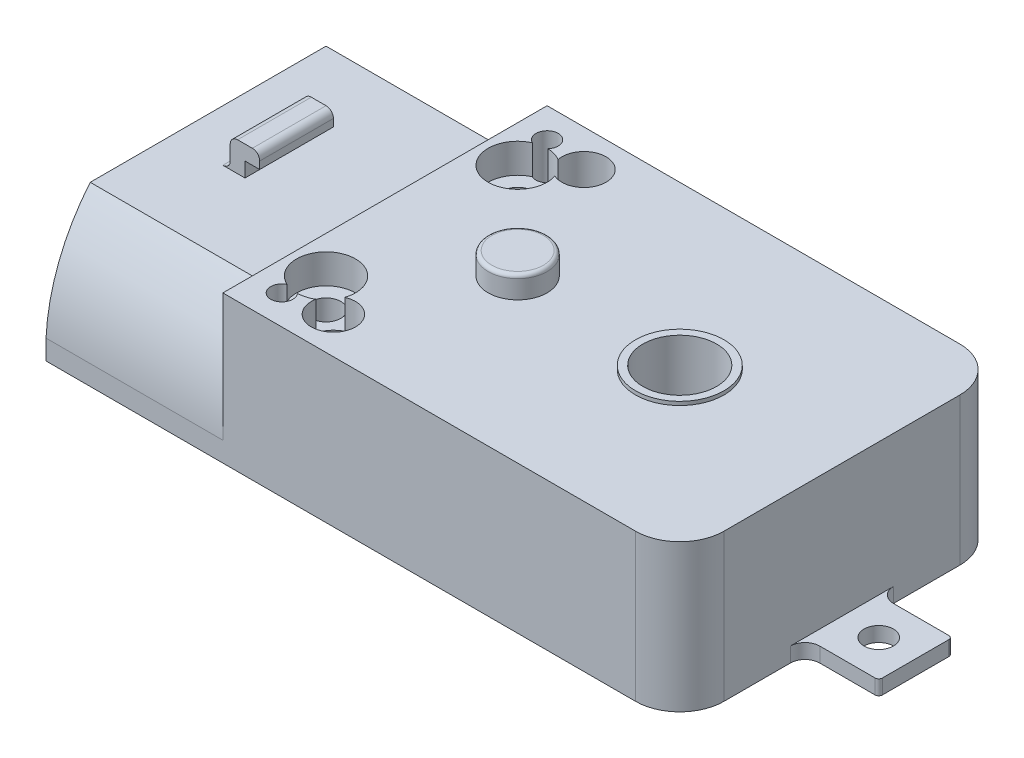
from build123d import *

# Parameters (mm, degrees)
BOSS_EXTRUDE2_DEPTH     = 9
SKETCH4_W               = 5
SKETCH4_H               = 1
BOSS_EXTRUDE3_DEPTH     = 5
SKETCH5_R               = 1
CUT_EXTRUDE1_DEPTH      = 5
FILLET1_R               = 1
FILLET2_R               = 1
FILLET3_R               = 3
FILLET4_R               = 3
BOSS_EXTRUDE4_DEPTH     = 12
FILLET6_R               = 0.25
SKETCH10_R              = 1.5
CUT_EXTRUDE7_DEPTH      = 44.13930922
CUT_EXTRUDE7_DEPTH_BACK = 44.13930922
SKETCH12_R              = 0.75
CUT_EXTRUDE8_DEPTH      = 3
SKETCH13_W              = 1
SKETCH13_H              = 5
BOSS_EXTRUDE5_DEPTH     = 2
SKETCH14_W              = 5
SKETCH14_H              = 1
BOSS_EXTRUDE6_DEPTH     = 1
FILLET7_R               = 0.5
FILLET8_R               = 0.5
FILLET9_R               = 0.5
CUT_EXTRUDE9_DEPTH      = 10
BOSS_EXTRUDE7_DEPTH     = 1
SKETCH18_R              = 1.5
CUT_EXTRUDE12_DEPTH     = 44.358966777
SKETCH19_R              = 0.75
CUT_EXTRUDE14_DEPTH     = 44.358966777
SKETCH20_R              = 2
BOSS_EXTRUDE8_DEPTH     = 1.5
FILLET10_R              = 0.25
SKETCH21_R              = 2.5
CUT_EXTRUDE15_DEPTH     = 5
SKETCH22_R              = 3
SKETCH22_R_2            = 2.5
BOSS_EXTRUDE9_DEPTH     = 0.25
SKETCH24_R              = 2
CUT_EXTRUDE16_DEPTH     = 2
SKETCH25_R              = 1
CUT_EXTRUDE17_DEPTH     = 5


with BuildPart() as part:
    # Sketch2 → Boss-Extrude2 (new body)
    with BuildSketch(Plane(origin=(0, 0, 0), x_dir=(1, 0, 0), z_dir=(0, 1, 0))):
        Polygon((0, 11), (31, 11), (31, 13.5), (31, 22), (0, 22), align=None)
        Polygon((31, 8.5), (31, 11), (0, 11), (0, 0), (31, 0), align=None)
    extrude(amount=BOSS_EXTRUDE2_DEPTH)

    # Sketch4 → Boss-Extrude3 (add)
    with BuildSketch(Plane(origin=(31, 0, 0), x_dir=(0, 0, -1), z_dir=(1, 0, 0))):
        with Locations((11, 0.5)):
            Rectangle(SKETCH4_W, SKETCH4_H)
    extrude(amount=BOSS_EXTRUDE3_DEPTH)

    # Sketch5 → Cut-Extrude1 (cut)
    with BuildSketch(Plane(origin=(0, 1, 0), x_dir=(1, 0, 0), z_dir=(0, 1, 0))):
        with Locations(Location((33.5, 11, 0), (0, 0, 270))):
            Circle(SKETCH5_R)
    extrude(amount=-CUT_EXTRUDE1_DEPTH, mode=Mode.SUBTRACT)

    # Fillet1
    fillet1_edges = [part.edges().sort_by_distance(p)[0] for p in [
        (31, 0.5, -8.5),
    ]]
    fillet(fillet1_edges, radius=FILLET1_R)

    # Fillet2
    fillet2_edges = [part.edges().sort_by_distance(p)[0] for p in [
        (31, 0.5, -13.5),
    ]]
    fillet(fillet2_edges, radius=FILLET2_R)

    # Fillet3
    fillet3_edges = [part.edges().sort_by_distance(p)[0] for p in [
        (31, 4.5, 0),
    ]]
    fillet(fillet3_edges, radius=FILLET3_R)

    # Fillet4
    fillet4_edges = [part.edges().sort_by_distance(p)[0] for p in [
        (31, 4.5, -22),
    ]]
    fillet(fillet4_edges, radius=FILLET4_R)

    # Sketch6 → Boss-Extrude4 (add)
    with BuildSketch(Plane.ZY):
        with BuildLine():
            Line((-22, 0), (-11, 0))
            Line((-11, 0), (-11, 9))
            Line((-11, 9), (-19, 9))
            ThreePointArc((-19, 9), (-21.121122912, 5.415884648), (-22, 1.344936316))
            Line((-22, 1.344936316), (-22, 0))
        make_face()
        with BuildLine():
            Line((-11, 9), (-11, 0))
            Line((-11, 0), (0, 0))
            Line((0, 0), (0, 1.344936316))
            ThreePointArc((0, 1.344936316), (-0.878877088, 5.415884648), (-3, 9))
            Line((-3, 9), (-11, 9))
        make_face()
    extrude(amount=BOSS_EXTRUDE4_DEPTH)

    # Fillet6
    fillet6_edges = [part.edges().sort_by_distance(p)[0] for p in [
        (36, 0.5, -13.5),
        (36, 0.5, -8.5),
    ]]
    fillet(fillet6_edges, radius=FILLET6_R)

    # Sketch10 → Cut-Extrude7 (cut, two sides)
    with BuildSketch(Plane(origin=(0, 9, 0), x_dir=(1, 0, 0), z_dir=(0, 1, 0))) as cut_extrude7_sk:
        with Locations(Location((5, 19.5, 0), (0, 0, 270))):
            Circle(SKETCH10_R)
        with Locations(Location((5, 2.5, 0), (0, 0, 270))):
            Circle(SKETCH10_R)
    extrude(amount=CUT_EXTRUDE7_DEPTH, mode=Mode.SUBTRACT)
    extrude(cut_extrude7_sk.sketch, amount=-CUT_EXTRUDE7_DEPTH_BACK, mode=Mode.SUBTRACT)

    # Sketch12 → Cut-Extrude8 (cut)
    with BuildSketch(Plane(origin=(0, 9, 0), x_dir=(1, 0, 0), z_dir=(0, 1, 0))):
        with Locations(Location((2, 2, 0), (0, 0, 270))):
            Circle(SKETCH12_R)
        with Locations(Location((2, 20, 0), (0, 0, 270))):
            Circle(SKETCH12_R)
    extrude(amount=-CUT_EXTRUDE8_DEPTH, mode=Mode.SUBTRACT)

    # Sketch13 → Boss-Extrude5 (add)
    with BuildSketch(Plane(origin=(0, 9, 0), x_dir=(1, 0, 0), z_dir=(0, 1, 0))):
        with Locations((-7.5, 11)):
            Rectangle(SKETCH13_W, SKETCH13_H)
    extrude(amount=BOSS_EXTRUDE5_DEPTH)

    # Sketch14 → Boss-Extrude6 (add)
    with BuildSketch(Plane(origin=(-7, 0, 0), x_dir=(0, 0, -1), z_dir=(1, 0, 0))):
        with Locations((11, 10.5)):
            Rectangle(SKETCH14_W, SKETCH14_H)
    extrude(amount=BOSS_EXTRUDE6_DEPTH)

    # Fillet7
    fillet7_edges = [part.edges().sort_by_distance(p)[0] for p in [
        (-8, 11, -11),
    ]]
    fillet(fillet7_edges, radius=FILLET7_R)

    # Fillet8
    fillet8_edges = [part.edges().sort_by_distance(p)[0] for p in [
        (-8, 9, -11),
    ]]
    fillet(fillet8_edges, radius=FILLET8_R)

    # Fillet9
    fillet9_edges = [part.edges().sort_by_distance(p)[0] for p in [
        (-6, 11, -11),
    ]]
    fillet(fillet9_edges, radius=FILLET9_R)

    # Sketch16 → Cut-Extrude9 (cut)
    with BuildSketch(Plane.ZY.offset(12)):
        with BuildLine():
            Line((-18.232108037, 8.359420628), (-3.767891963, 8.359420628))
            ThreePointArc((-3.767891963, 8.359420628), (-1.809932353, 5.051006457), (-0.998661194, 1.293207997))
            Line((-0.998661194, 1.293207997), (-0.998661194, 0))
            Line((-0.998661194, 0), (-21, 0))
            Line((-21, 0), (-21.001338806, 1.293207997))
            ThreePointArc((-21.001338806, 1.293207997), (-20.190067647, 5.051006457), (-18.232108037, 8.359420628))
        make_face()
    extrude(amount=-CUT_EXTRUDE9_DEPTH, mode=Mode.SUBTRACT)

    # Sketch17 → Boss-Extrude7 (add)
    with BuildSketch(Plane(origin=(0, 9, 0), x_dir=(1, 0, 0), z_dir=(0, 1, 0))):
        with BuildLine():
            Line((0, 3), (0, 19))
            Line((0, 19), (0, 22))
            Line((0, 22), (28, 22))
            ThreePointArc((28, 22), (30.121320344, 21.121320344), (31, 19))
            Line((31, 19), (31, 3))
            ThreePointArc((31, 3), (30.121320344, 0.878679656), (28, 0))
            Line((28, 0), (0, 0))
            Line((0, 0), (0, 3))
        make_face()
    extrude(amount=BOSS_EXTRUDE7_DEPTH)

    # Sketch18 → Cut-Extrude12 (cut, through all)
    with BuildSketch(Plane(origin=(0, 10, 0), x_dir=(1, 0, 0), z_dir=(0, 1, 0))):
        with Locations(Location((5, 19.5, 0), (0, 0, 270))):
            Circle(SKETCH18_R)
        with Locations(Location((5, 2.5, 0), (0, 0, 270))):
            Circle(SKETCH18_R)
    extrude(amount=-CUT_EXTRUDE12_DEPTH, mode=Mode.SUBTRACT)

    # Sketch19 → Cut-Extrude14 (cut, through all)
    with BuildSketch(Plane(origin=(0, 10, 0), x_dir=(1, 0, 0), z_dir=(0, 1, 0))):
        with Locations(Location((2, 20, 0), (0, 0, 270))):
            Circle(SKETCH19_R)
        with Locations(Location((2, 2, 0), (0, 0, 270))):
            Circle(SKETCH19_R)
    extrude(amount=-CUT_EXTRUDE14_DEPTH, mode=Mode.SUBTRACT)

    # Sketch20 → Boss-Extrude8 (add)
    with BuildSketch(Plane(origin=(0, 10, 0), x_dir=(1, 0, 0), z_dir=(0, 1, 0))):
        with Locations(Location((9, 11, 0), (0, 0, 270))):
            Circle(SKETCH20_R)
    extrude(amount=BOSS_EXTRUDE8_DEPTH)

    # Fillet10
    fillet10_edges = [part.edges().sort_by_distance(p)[0] for p in [
        (9, 11.5, -13),
    ]]
    fillet(fillet10_edges, radius=FILLET10_R)

    # Sketch21 → Cut-Extrude15 (cut)
    with BuildSketch(Plane(origin=(0, 10, 0), x_dir=(1, 0, 0), z_dir=(0, 1, 0))):
        with Locations(Location((20, 11, 0), (0, 0, 270))):
            Circle(SKETCH21_R)
    extrude(amount=-CUT_EXTRUDE15_DEPTH, mode=Mode.SUBTRACT)

    # Sketch22 → Boss-Extrude9 (add)
    with BuildSketch(Plane(origin=(0, 10, 0), x_dir=(1, 0, 0), z_dir=(0, 1, 0))):
        with Locations(Location((20, 11, 0), (0, 0, 270))):
            Circle(SKETCH22_R)
        with Locations(Location((20, 11, 0), (0, 0, 270))):
            Circle(SKETCH22_R_2, mode=Mode.SUBTRACT)
    extrude(amount=BOSS_EXTRUDE9_DEPTH)

    # Sketch24 → Cut-Extrude16 (cut)
    with BuildSketch(Plane(origin=(0, 10, 0), x_dir=(1, 0, 0), z_dir=(0, 1, 0))):
        with Locations((2.5, 17.5)):
            Circle(SKETCH24_R)
        with Locations((2.5, 4.5)):
            Circle(SKETCH24_R)
    extrude(amount=-CUT_EXTRUDE16_DEPTH, mode=Mode.SUBTRACT)

    # Sketch25 → Cut-Extrude17 (cut)
    with BuildSketch(Plane(origin=(0, 10, 0), x_dir=(1, 0, 0), z_dir=(0, 1, 0))):
        with Locations(Location((2.5, 17.5, 0), (0, 0, 270))):
            Circle(SKETCH25_R)
        with Locations(Location((2.5, 4.5, 0), (0, 0, 270))):
            Circle(SKETCH25_R)
    extrude(amount=-CUT_EXTRUDE17_DEPTH, mode=Mode.SUBTRACT)


solid = part.part
